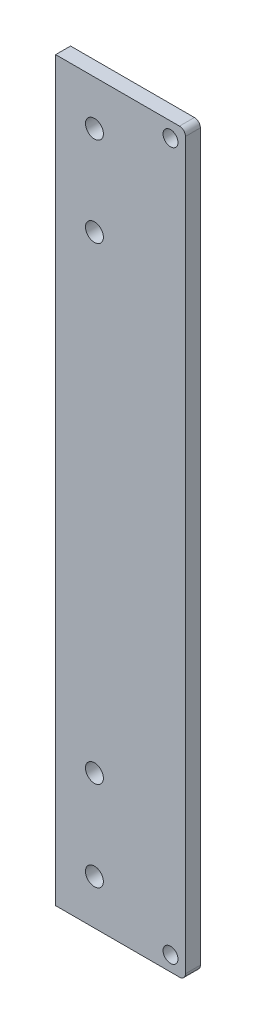
from build123d import *

# Parameters (mm, degrees)
SKETCH1_R           = 2.5
BOSS_EXTRUDE1_DEPTH = 5
SKETCH2_R           = 1.5
SKETCH2_W           = 50
SKETCH2_H           = 50
CUT_EXTRUDE1_DEPTH  = 5
SKETCH3_W           = 250
SKETCH3_H           = 300
CUT_EXTRUDE2_DEPTH  = 10
SKETCH4_R           = 3
CUT_EXTRUDE3_DEPTH  = 10


with BuildPart() as part:
    # Sketch1 → Boss-Extrude1 (new body)
    with BuildSketch(Plane.XY):
        with BuildLine():
            Line((-123.5, 121.5), (-123.5, -121.5))
            ThreePointArc((-123.5, -121.5), (-122.914213562, -122.914213562), (-121.5, -123.5))
            Line((-121.5, -123.5), (121.5, -123.5))
            ThreePointArc((121.5, -123.5), (122.914213562, -122.914213562), (123.5, -121.5))
            Line((123.5, -121.5), (123.5, 121.5))
            ThreePointArc((123.5, 121.5), (122.914213562, 122.914213562), (121.5, 123.5))
            Line((121.5, 123.5), (-121.5, 123.5))
            ThreePointArc((-121.5, 123.5), (-122.914213562, 122.914213562), (-123.5, 121.5))
        make_face()
        with Locations((-118.5, 118.5)):
            Circle(SKETCH1_R, mode=Mode.SUBTRACT)
        with Locations((118.5, 118.5)):
            Circle(SKETCH1_R, mode=Mode.SUBTRACT)
        with Locations((118.5, -118.5)):
            Circle(SKETCH1_R, mode=Mode.SUBTRACT)
        with Locations((-118.5, -118.5)):
            Circle(SKETCH1_R, mode=Mode.SUBTRACT)
    extrude(amount=BOSS_EXTRUDE1_DEPTH)

    # Sketch2 → Cut-Extrude1 (cut)
    with BuildSketch(Plane(origin=(0, 0, 0), x_dir=(-1, 0, 0), z_dir=(0, 0, -1))):
        with Locations((28.284271247, 28.284271247)):
            Circle(SKETCH2_R)
        with Locations((28.284271247, -28.284271247)):
            Circle(SKETCH2_R)
        with Locations((-28.284271247, -28.284271247)):
            Circle(SKETCH2_R)
        with Locations((-28.284271247, 28.284271247)):
            Circle(SKETCH2_R)
        Rectangle(SKETCH2_W, SKETCH2_H)
    extrude(amount=-CUT_EXTRUDE1_DEPTH, mode=Mode.SUBTRACT)

    # Sketch3 → Cut-Extrude2 (cut)
    with BuildSketch(Plane(origin=(0, 0, 0), x_dir=(-1, 0, 0), z_dir=(0, 0, -1))):
        with Locations((45, 0)):
            Rectangle(SKETCH3_W, SKETCH3_H)
    extrude(amount=-CUT_EXTRUDE2_DEPTH, mode=Mode.SUBTRACT)

    # Sketch4 → Cut-Extrude3 (cut)
    with BuildSketch(Plane(origin=(0, 0, 0), x_dir=(-1, 0, 0), z_dir=(0, 0, -1))):
        with Locations((-93, 78.5)):
            Circle(SKETCH4_R)
        with Locations((-93, 108.5)):
            Circle(SKETCH4_R)
        with Locations((-93, -78.5)):
            Circle(SKETCH4_R)
        with Locations((-93, -108.5)):
            Circle(SKETCH4_R)
    extrude(amount=-CUT_EXTRUDE3_DEPTH, mode=Mode.SUBTRACT)


solid = part.part
